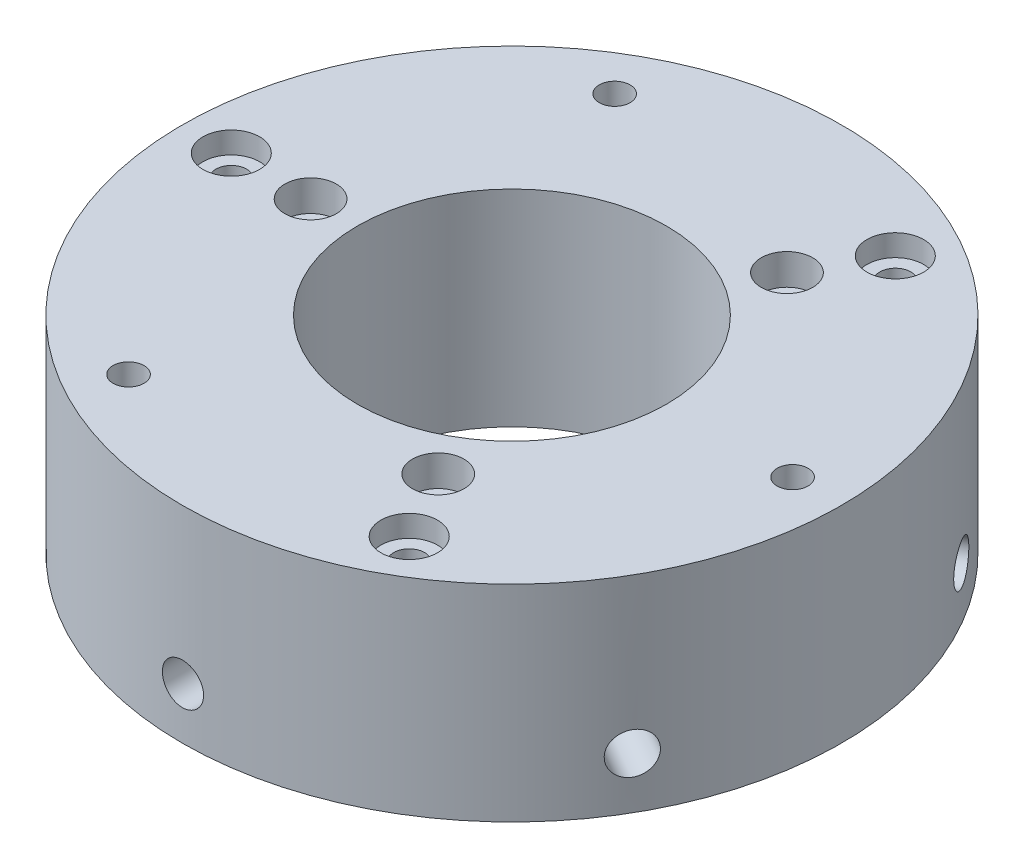
from build123d import *

# Parameters (mm, degrees)
SKETCH_1_R               = 32
SKETCH_1_R_2             = 2.5
SKETCH_1_R_3             = 1.5
EXTRUDE_1_DEPTH          = 20
SKETCH_2_R               = 2.75
CUT_EXTRUDE_1_DEPTH      = 2.1
SKETCH_3_R               = 2.5
CUT_EXTRUDE_2_DEPTH      = 3
SKETCH_4_R               = 2
CUT_EXTRUDE_3_DEPTH      = 10
PATTERN_CIRCULAR_1_COUNT = 6
SKETCH_5_R               = 15
CUT_EXTRUDE_4_DEPTH      = 21.0000001
SKETCH_6_R               = 2.75
SKETCH_6_R_2             = 1.5
CUT_EXTRUDE_5_DEPTH      = 3


with BuildPart() as part:
    # 草图1 → 凸台-拉伸1 (new body)
    with BuildSketch(Plane(origin=(0, 0, 0), x_dir=(1, 0, 0), z_dir=(0, 1, 0))):
        Circle(SKETCH_1_R)
        with Locations((-23.599192253, -13.625)):
            Circle(SKETCH_1_R_2, mode=Mode.SUBTRACT)
        with Locations((-13.625, -23.599192253)):
            Circle(SKETCH_1_R_3, mode=Mode.SUBTRACT)
        with Locations((0, -27.25)):
            Circle(SKETCH_1_R_2, mode=Mode.SUBTRACT)
        with Locations((13.625, -23.599192253)):
            Circle(SKETCH_1_R_3, mode=Mode.SUBTRACT)
        with Locations((23.599192253, -13.625)):
            Circle(SKETCH_1_R_2, mode=Mode.SUBTRACT)
        with Locations((27.25, 0)):
            Circle(SKETCH_1_R_3, mode=Mode.SUBTRACT)
        with Locations((23.599192253, 13.625)):
            Circle(SKETCH_1_R_2, mode=Mode.SUBTRACT)
        with Locations((13.625, 23.599192253)):
            Circle(SKETCH_1_R_3, mode=Mode.SUBTRACT)
        with Locations((0, 27.25)):
            Circle(SKETCH_1_R_2, mode=Mode.SUBTRACT)
        with Locations((-13.625, 23.599192253)):
            Circle(SKETCH_1_R_3, mode=Mode.SUBTRACT)
        with Locations((-23.599192253, 13.625)):
            Circle(SKETCH_1_R_2, mode=Mode.SUBTRACT)
        with Locations((-27.25, 0)):
            Circle(SKETCH_1_R_3, mode=Mode.SUBTRACT)
        with Locations((-23.599192253, -13.625)):
            Circle(SKETCH_1_R_2)
        with Locations((-23.599192253, 13.625)):
            Circle(SKETCH_1_R_2)
        with Locations((23.599192253, 13.625)):
            Circle(SKETCH_1_R_2)
        with Locations((0, 27.25)):
            Circle(SKETCH_1_R_2)
        with Locations((0, -27.25)):
            Circle(SKETCH_1_R_2)
        with Locations((23.599192253, -13.625)):
            Circle(SKETCH_1_R_2)
    extrude(amount=EXTRUDE_1_DEPTH)

    # 草图2 → 切除-拉伸1 (cut)
    with BuildSketch(Plane(origin=(0, 20, 0), x_dir=(1, 0, 0), z_dir=(0, 1, 0))):
        with Locations((-27.25, 0)):
            Circle(SKETCH_2_R)
        with Locations((13.625, 23.599192253)):
            Circle(SKETCH_2_R)
        with Locations((13.625, -23.599192253)):
            Circle(SKETCH_2_R)
    extrude(amount=-CUT_EXTRUDE_1_DEPTH, mode=Mode.SUBTRACT)

    # 草图3 → 切除-拉伸2 (cut)
    with BuildSketch(Plane(origin=(0, 20, 0), x_dir=(1, 0, 0), z_dir=(0, 1, 0))):
        with Locations((-19.55, 0)):
            Circle(SKETCH_3_R)
        with Locations((9.775, 16.930796644)):
            Circle(SKETCH_3_R)
        with Locations((9.775, -16.930796644)):
            Circle(SKETCH_3_R)
    extrude(amount=-CUT_EXTRUDE_2_DEPTH, mode=Mode.SUBTRACT)

    # 草图4 → 切除-拉伸3 (cut)
    with BuildSketch(Plane.XY.offset(32)):
        with Locations((0, 5)):
            Circle(SKETCH_4_R)
    cut_extrude_3 = extrude(amount=-CUT_EXTRUDE_3_DEPTH, mode=Mode.SUBTRACT)

    # 阵列(圆周)1: 切除-拉伸3 ×6 about axis
    pattern_circular_1_axis = Axis((0, 0, 0), (0, 1, 0))
    for i in range(1, PATTERN_CIRCULAR_1_COUNT):
        add(cut_extrude_3.rotate(pattern_circular_1_axis, i * 360 / PATTERN_CIRCULAR_1_COUNT), mode=Mode.SUBTRACT)

    # 草图5 → 切除-拉伸4 (cut, through all)
    with BuildSketch(Plane(origin=(0, 20, 0), x_dir=(1, 0, 0), z_dir=(0, 1, 0))):
        Circle(SKETCH_5_R)
    extrude(amount=-CUT_EXTRUDE_4_DEPTH, mode=Mode.SUBTRACT)

    # 草图6 → 切除-拉伸5 (cut)
    with BuildSketch(Plane.XZ):
        with Locations((13.625, -23.599192253)):
            Circle(SKETCH_6_R)
        with Locations((13.625, -23.599192253)):
            Circle(SKETCH_6_R_2, mode=Mode.SUBTRACT)
        with Locations((27.25, 0)):
            Circle(SKETCH_6_R)
        with Locations((27.25, 0)):
            Circle(SKETCH_6_R_2, mode=Mode.SUBTRACT)
        with Locations((13.625, 23.599192253)):
            Circle(SKETCH_6_R)
        with Locations((13.625, 23.599192253)):
            Circle(SKETCH_6_R_2, mode=Mode.SUBTRACT)
        with Locations((-13.625, 23.599192253)):
            Circle(SKETCH_6_R)
        with Locations((-13.625, 23.599192253)):
            Circle(SKETCH_6_R_2, mode=Mode.SUBTRACT)
        with Locations((-27.25, 0)):
            Circle(SKETCH_6_R)
        with Locations((-27.25, 0)):
            Circle(SKETCH_6_R_2, mode=Mode.SUBTRACT)
        with Locations((-13.625, -23.599192253)):
            Circle(SKETCH_6_R)
        with Locations((-13.625, -23.599192253)):
            Circle(SKETCH_6_R_2, mode=Mode.SUBTRACT)
    extrude(amount=-CUT_EXTRUDE_5_DEPTH, mode=Mode.SUBTRACT)


solid = part.part
